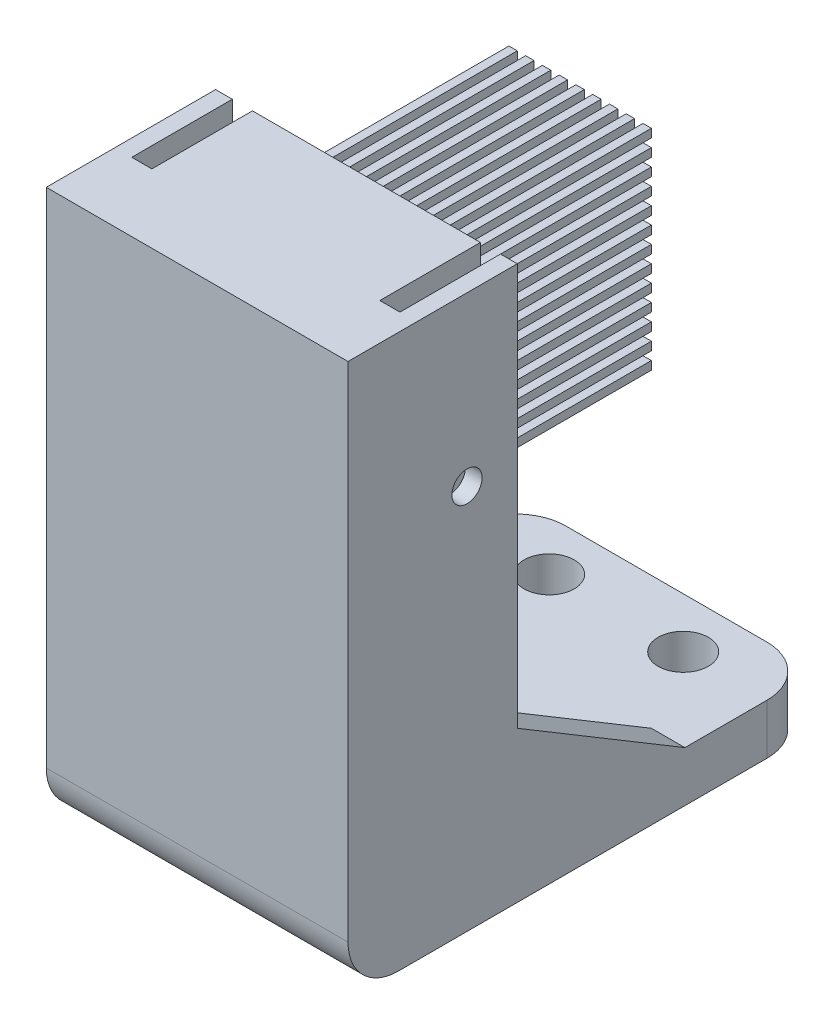
from build123d import *

# Parameters (mm, degrees)
EXTRUDE_1_DEPTH        = 30
SKETCH_2_W             = 18
SKETCH_2_H             = 28
SKETCH_2_R             = 1.5
EXTRUDE_2_DEPTH        = 3
SKETCH_3_W             = 1.2
SKETCH_3_H             = 6
CUT_EXTRUDE_1_DEPTH    = 15
SKETCH_4_R             = 0.9
CUT_EXTRUDE_2_DEPTH    = 18
FILLET_1_R             = 3
EXTRUDE_3_DEPTH        = 2
EXTRUDE_4_DEPTH        = 5
FILLET_2_R             = 3
EXTRUDE_5_DEPTH        = 25
SKETCH_9_W             = 9
SKETCH_9_H             = 13
EXTRUDE_6_DEPTH        = 13
SKETCH_10_R            = 0.9
CUT_EXTRUDE_3_DEPTH    = 19
SKETCH_11_W            = 0.5
SKETCH_11_H            = 0.5
CUT_EXTRUDE_4_DEPTH    = 13
SKETCH_12_W            = 9
SKETCH_12_H            = 0.5
CUT_EXTRUDE_5_DEPTH    = 13
PATTERN_LINEAR_1_COUNT = 13
PATTERN_LINEAR_1_PITCH = 1


with BuildPart() as part:
    # 草图1 → 凸台-拉伸1 (new body)
    with BuildSketch(Plane(origin=(0, 0, 0), x_dir=(1, 0, 0), z_dir=(0, 1, 0))):
        Polygon((-9, 10.1), (-9, 0), (9, 0), (9, 10.1), (4.5, 10.1), (4.5, 8.1), (6, 8.1), (6, 2), (-6, 2), (-6, 8.1), (-4.5, 8.1), (-4.5, 10.1), align=None)
    extrude(amount=EXTRUDE_1_DEPTH)

    # 草图2 → 凸台-拉伸2 (add)
    with BuildSketch(Plane.XZ):
        with Locations((0, -14)):
            Rectangle(SKETCH_2_W, SKETCH_2_H)
        with Locations((4, -25)):
            Circle(SKETCH_2_R, mode=Mode.SUBTRACT)
        with Locations((-4, -25)):
            Circle(SKETCH_2_R, mode=Mode.SUBTRACT)
    extrude(amount=EXTRUDE_2_DEPTH)

    # 草图3 → 切除-拉伸1 (cut)
    with BuildSketch(Plane(origin=(0, 30, 0), x_dir=(1, 0, 0), z_dir=(0, 1, 0))):
        with Locations((-7.4, 7.1)):
            Rectangle(SKETCH_3_W, SKETCH_3_H)
        with Locations((7.4, 7.1)):
            Rectangle(SKETCH_3_W, SKETCH_3_H)
    extrude(amount=-CUT_EXTRUDE_1_DEPTH, mode=Mode.SUBTRACT)

    # 草图4 → 切除-拉伸2 (cut)
    with BuildSketch(Plane.ZY.offset(9)):
        with Locations((-7.1, 20)):
            Circle(SKETCH_4_R)
    extrude(amount=-CUT_EXTRUDE_2_DEPTH, mode=Mode.SUBTRACT)

    # 圆角1
    fillet_1_edges = [part.edges().sort_by_distance(p)[0] for p in [
        (9, -1.5, -28),
        (-9, -1.5, -28),
    ]]
    fillet(fillet_1_edges, radius=FILLET_1_R)

    # 草图5 → 凸台-拉伸3 (add)
    with BuildSketch(Plane.ZY.offset(9)):
        Polygon((-10.1, 0), (-10.1, 6), (-20.1, 0), align=None)
    extrude_3 = extrude(amount=-EXTRUDE_3_DEPTH)

    # 镜向1: 凸台-拉伸3 across plane
    add(extrude_3.mirror(Plane(origin=(0, 0, 0), x_dir=(0, 0, 1), z_dir=(1, 0, 0))))

    # 草图6 → 凸台-拉伸4 (add)
    with BuildSketch(Plane(origin=(0, 0, 0), x_dir=(1, 0, 0), z_dir=(0, 1, 0))):
        Polygon((-6, 2), (6, 2), (6, 8.1), (4.5, 8.1), (4.5, 10.1), (-4.5, 10.1), (-4.5, 8.1), (-6, 8.1), align=None)
    extrude(amount=EXTRUDE_4_DEPTH)

    # 圆角2
    fillet_2_edges = [part.edges().sort_by_distance(p)[0] for p in [
        (0, -3, 0),
    ]]
    fillet(fillet_2_edges, radius=FILLET_2_R)

    # 草图8 → 凸台-拉伸5 (add)
    with BuildSketch(Plane(origin=(0, 30, 0), x_dir=(1, 0, 0), z_dir=(0, 1, 0))):
        Polygon((-6, 2), (6, 2), (6, 8.1), (4.5, 8.1), (4.5, 10.1), (-4.5, 10.1), (-4.5, 8.1), (-6, 8.1), align=None)
    extrude(amount=-EXTRUDE_5_DEPTH)

    # 草图9 → 凸台-拉伸6 (add)
    with BuildSketch(Plane(origin=(0, 0, -10.1), x_dir=(-1, 0, 0), z_dir=(0, 0, -1))):
        with Locations((0, 21.5)):
            Rectangle(SKETCH_9_W, SKETCH_9_H)
    extrude(amount=EXTRUDE_6_DEPTH)

    # 草图10 → 切除-拉伸3 (cut, through all)
    with BuildSketch(Plane.ZY.offset(9)):
        with Locations((-7.1, 20)):
            Circle(SKETCH_10_R)
    extrude(amount=-CUT_EXTRUDE_3_DEPTH, mode=Mode.SUBTRACT)

    # 草图11 → 切除-拉伸4 (cut)
    with BuildSketch(Plane(origin=(0, 0, -23.1), x_dir=(-1, 0, 0), z_dir=(0, 0, -1))):
        with Locations((3.75, 27.75)):
            Rectangle(SKETCH_11_W, SKETCH_11_H)
        with Locations((2.75, 27.75)):
            Rectangle(SKETCH_11_W, SKETCH_11_H)
        with Locations((1.75, 27.75)):
            Rectangle(SKETCH_11_W, SKETCH_11_H)
        with Locations((0.75, 27.75)):
            Rectangle(SKETCH_11_W, SKETCH_11_H)
        with Locations((-0.25, 27.75)):
            Rectangle(SKETCH_11_W, SKETCH_11_H)
        with Locations((-1.25, 27.75)):
            Rectangle(SKETCH_11_W, SKETCH_11_H)
        with Locations((-2.25, 27.75)):
            Rectangle(SKETCH_11_W, SKETCH_11_H)
        with Locations((-3.25, 27.75)):
            Rectangle(SKETCH_11_W, SKETCH_11_H)
        with Locations((-4.25, 27.75)):
            Rectangle(SKETCH_11_W, SKETCH_11_H)
    cut_extrude_4 = extrude(amount=-CUT_EXTRUDE_4_DEPTH, mode=Mode.SUBTRACT)

    # 草图12 → 切除-拉伸5 (cut)
    with BuildSketch(Plane(origin=(0, 0, -23.1), x_dir=(-1, 0, 0), z_dir=(0, 0, -1))):
        with Locations((0, 27.25)):
            Rectangle(SKETCH_12_W, SKETCH_12_H)
    cut_extrude_5 = extrude(amount=-CUT_EXTRUDE_5_DEPTH, mode=Mode.SUBTRACT)

    # 阵列(线性)1: 切除-拉伸4, 切除-拉伸5 ×13
    with Locations(*[(0, -i * PATTERN_LINEAR_1_PITCH, 0) for i in range(1, PATTERN_LINEAR_1_COUNT)]):
        add(cut_extrude_4, mode=Mode.SUBTRACT)
        add(cut_extrude_5, mode=Mode.SUBTRACT)


solid = part.part
